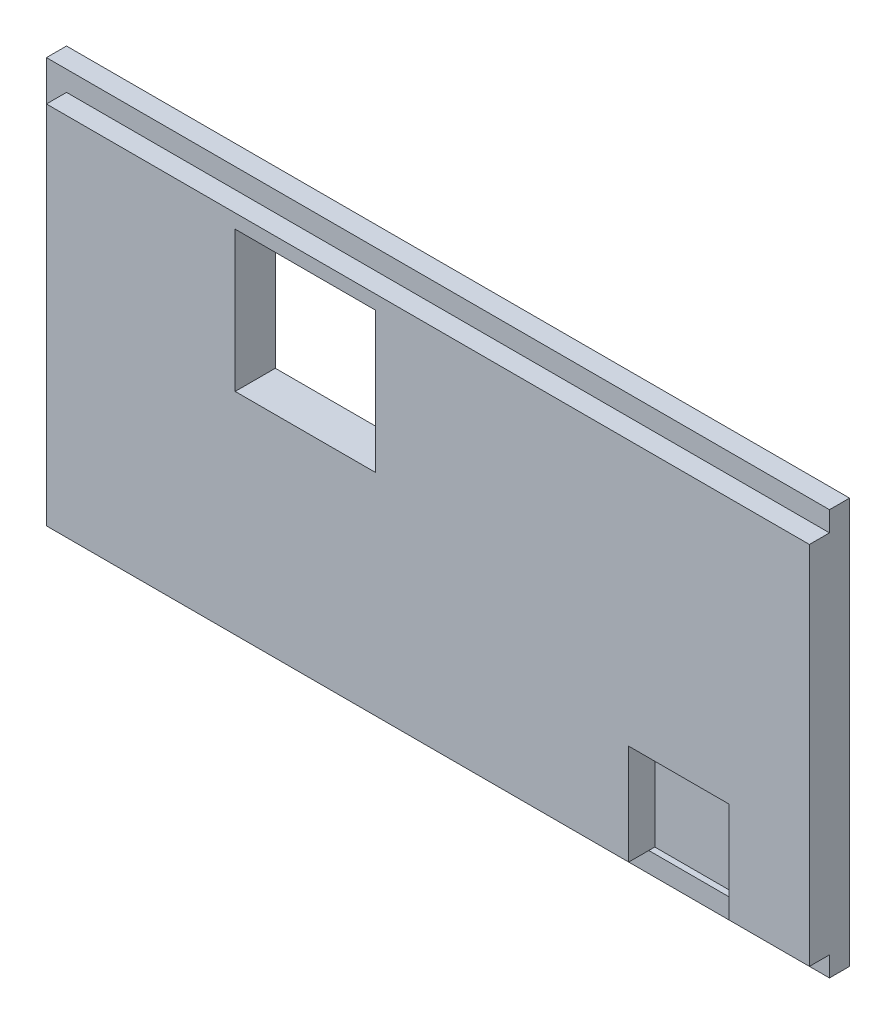
from build123d import *

# Parameters (mm, degrees)
SKETCH1_W           = 39
SKETCH1_H           = 20.2
BOSS_EXTRUDE1_DEPTH = 1
SKETCH2_W           = 38
SKETCH2_H           = 18.2
BOSS_EXTRUDE2_DEPTH = 1
SKETCH3_W           = 7
SKETCH3_H           = 7
CUT_EXTRUDE1_DEPTH  = 21
SKETCH4_W           = 5
SKETCH4_H           = 5
CUT_EXTRUDE2_DEPTH  = 1.3


with BuildPart() as part:
    # Sketch1 → Boss-Extrude1 (new body)
    with BuildSketch(Plane.XY):
        Rectangle(SKETCH1_W, SKETCH1_H)
    extrude(amount=BOSS_EXTRUDE1_DEPTH)

    # Sketch2 → Boss-Extrude2 (add)
    with BuildSketch(Plane.XY.offset(1)):
        with Locations((0.5, 0)):
            Rectangle(SKETCH2_W, SKETCH2_H)
    extrude(amount=BOSS_EXTRUDE2_DEPTH)

    # Sketch3 → Cut-Extrude1 (cut)
    with BuildSketch(Plane.XY.offset(2)):
        with Locations((-5.6, 4.9)):
            Rectangle(SKETCH3_W, SKETCH3_H)
    extrude(amount=-CUT_EXTRUDE1_DEPTH, mode=Mode.SUBTRACT)

    # Sketch4 → Cut-Extrude2 (cut)
    with BuildSketch(Plane.XY.offset(2)):
        with Locations((13, -6.6)):
            Rectangle(SKETCH4_W, SKETCH4_H)
    extrude(amount=-CUT_EXTRUDE2_DEPTH, mode=Mode.SUBTRACT)


solid = part.part
